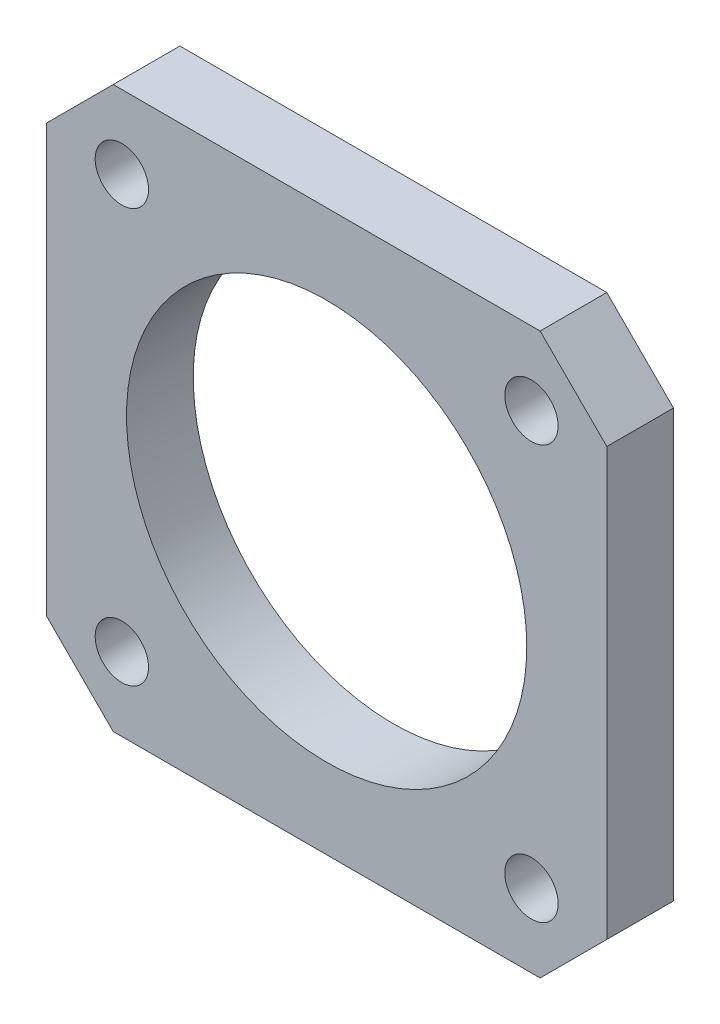
from build123d import *

# Parameters (mm, degrees)
SKETCH1_W           = 42
SKETCH1_H           = 42
BOSS_EXTRUDE1_DEPTH = 5
SKETCH2_R           = 15
CUT_EXTRUDE1_DEPTH  = 6
SKETCH4_R           = 2
CUT_EXTRUDE3_DEPTH  = 5
CHAMFER1_SIZE       = 5


with BuildPart() as part:
    # Sketch1 → Boss-Extrude1 (new body)
    with BuildSketch(Plane.XY):
        with Locations((21, 21)):
            Rectangle(SKETCH1_W, SKETCH1_H)
    extrude(amount=BOSS_EXTRUDE1_DEPTH)

    # Sketch2 → Cut-Extrude1 (cut, through all)
    with BuildSketch(Plane.XY.offset(5)):
        with Locations((21, 21)):
            Circle(SKETCH2_R)
    extrude(amount=-CUT_EXTRUDE1_DEPTH, mode=Mode.SUBTRACT)

    # Sketch4 → Cut-Extrude3 (cut)
    with BuildSketch(Plane.XY.offset(5)):
        with Locations((5.65, 36.5)):
            Circle(SKETCH4_R)
        with Locations((5.65, 5.5)):
            Circle(SKETCH4_R)
        with Locations((36.35, 5.5)):
            Circle(SKETCH4_R)
        with Locations((36.35, 36.5)):
            Circle(SKETCH4_R)
    extrude(amount=-CUT_EXTRUDE3_DEPTH, mode=Mode.SUBTRACT)

    # Chamfer1
    chamfer1_edges = [part.edges().sort_by_distance(p)[0] for p in [
        (0, 42, 2.5),
        (42, 42, 2.5),
        (42, 0, 2.5),
        (0, 0, 2.5),
    ]]
    chamfer(chamfer1_edges, length=CHAMFER1_SIZE)


solid = part.part
